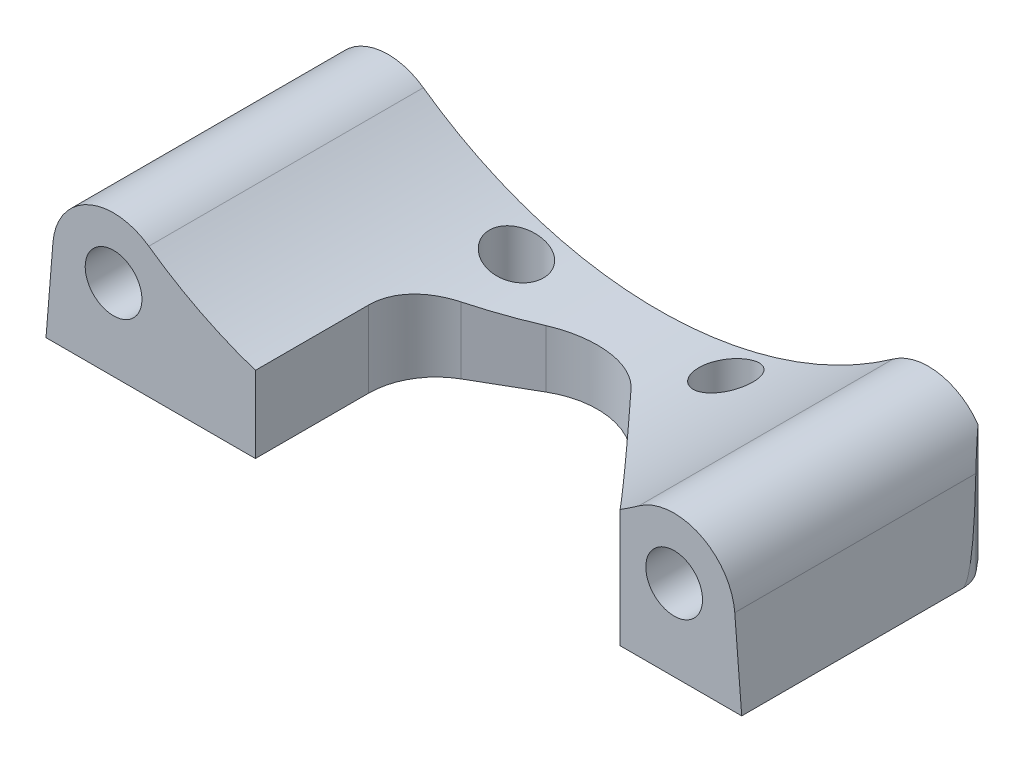
from build123d import *

# Parameters (mm, degrees)
SKETCH1_R           = 4.2
BOSS_EXTRUDE1_DEPTH = 40.65
SKETCH2_R           = 4.2
BOSS_EXTRUDE2_DEPTH = 18
SKETCH3_R           = 4
CUT_EXTRUDE1_DEPTH  = 22
SKETCH4_R           = 2.6
CUT_EXTRUDE2_DEPTH  = 6
CHAMFER1_SIZE       = 1
CUT_EXTRUDE3_DEPTH  = 22


with BuildPart() as part:
    # Sketch1 → Boss-Extrude1 (new body)
    with BuildSketch(Plane.XY):
        with BuildLine():
            Line((-48.970703673, 12.725586394), (-50, 0))
            Line((-50, 0), (50, 0))
            Line((50, 0), (48.970703673, 12.725586394))
            ThreePointArc((48.970703673, 12.725586394), (43.799691423, 20.158574942), (34.782608696, 19.333404937))
            ThreePointArc((34.782608696, 19.333404937), (0, 8.222771187), (-34.782608696, 19.333404937))
            ThreePointArc((-34.782608696, 19.333404937), (-43.799691423, 20.158574942), (-48.970703673, 12.725586394))
        make_face()
        with Locations((-40, 12)):
            Circle(SKETCH1_R, mode=Mode.SUBTRACT)
        with Locations((40, 12)):
            Circle(SKETCH1_R, mode=Mode.SUBTRACT)
    extrude(amount=BOSS_EXTRUDE1_DEPTH)

    # Sketch2 → Boss-Extrude2 (add)
    with BuildSketch(Plane(origin=(0, 0, 0), x_dir=(-1, 0, 0), z_dir=(0, 0, -1))):
        with Locations((-40, 12)):
            Circle(SKETCH2_R)
        with Locations((40, 12)):
            Circle(SKETCH2_R)
    extrude(amount=-BOSS_EXTRUDE2_DEPTH)

    # Sketch3 → Cut-Extrude1 (cut, through all)
    with BuildSketch(Plane.XZ):
        with Locations((-15.5, 5.5)):
            Circle(SKETCH3_R)
        with Locations((15.5, 5.5)):
            Circle(SKETCH3_R)
        with BuildLine():
            Line((8.764674023, 12.803629506), (32, 37.65))
            Line((32, 37.65), (50, 37.65))
            Line((50, 37.65), (50, 40.65))
            Line((50, 40.65), (-19, 40.65))
            Line((-19, 40.65), (-19, 23.886751346))
            ThreePointArc((-19, 23.886751346), (-17.660254038, 18.886751346), (-14, 15.226497308))
            Line((-14, 15.226497308), (-6, 10.607695155))
            ThreePointArc((-6, 10.607695155), (1.765329298, 9.130559724), (8.764674023, 12.803629506))
        make_face()
    extrude(amount=-CUT_EXTRUDE1_DEPTH, mode=Mode.SUBTRACT)

    # Sketch4 → Cut-Extrude2 (cut)
    with BuildSketch(Plane.XZ):
        with Locations((-32, 27.65)):
            Circle(SKETCH4_R)
        with Locations((-45, 5)):
            Circle(SKETCH4_R)
        with Locations((32, 27.65)):
            Circle(SKETCH4_R)
        with Locations((45, 5)):
            Circle(SKETCH4_R)
    extrude(amount=-CUT_EXTRUDE2_DEPTH, mode=Mode.SUBTRACT)

    # Chamfer1
    chamfer1_edges = [part.edges().sort_by_distance(p)[0] for p in [
        (-34.6, 0, 27.65),
        (-47.6, 0, 5),
        (29.4, 0, 27.65),
        (42.4, 0, 5),
    ]]
    chamfer(chamfer1_edges, length=CHAMFER1_SIZE)

    # Sketch5 → Cut-Extrude3 (cut, through all)
    with BuildSketch(Plane.XZ):
        with BuildLine():
            Line((-50, 5), (-50, 0))
            Line((-50, 0), (-47.331538291, 0))
            Line((-47.331538291, 0), (-48.830222216, 1.786061952))
            ThreePointArc((-48.830222216, 1.786061952), (-49.698463104, 3.289899283), (-50, 5))
        make_face()
        with BuildLine():
            Line((48.830222216, 1.786061952), (47.331538291, 0))
            Line((47.331538291, 0), (50, 0))
            Line((50, 0), (50, 5))
            ThreePointArc((50, 5), (49.698463104, 3.289899283), (48.830222216, 1.786061952))
        make_face()
    extrude(amount=-CUT_EXTRUDE3_DEPTH, mode=Mode.SUBTRACT)


solid = part.part
